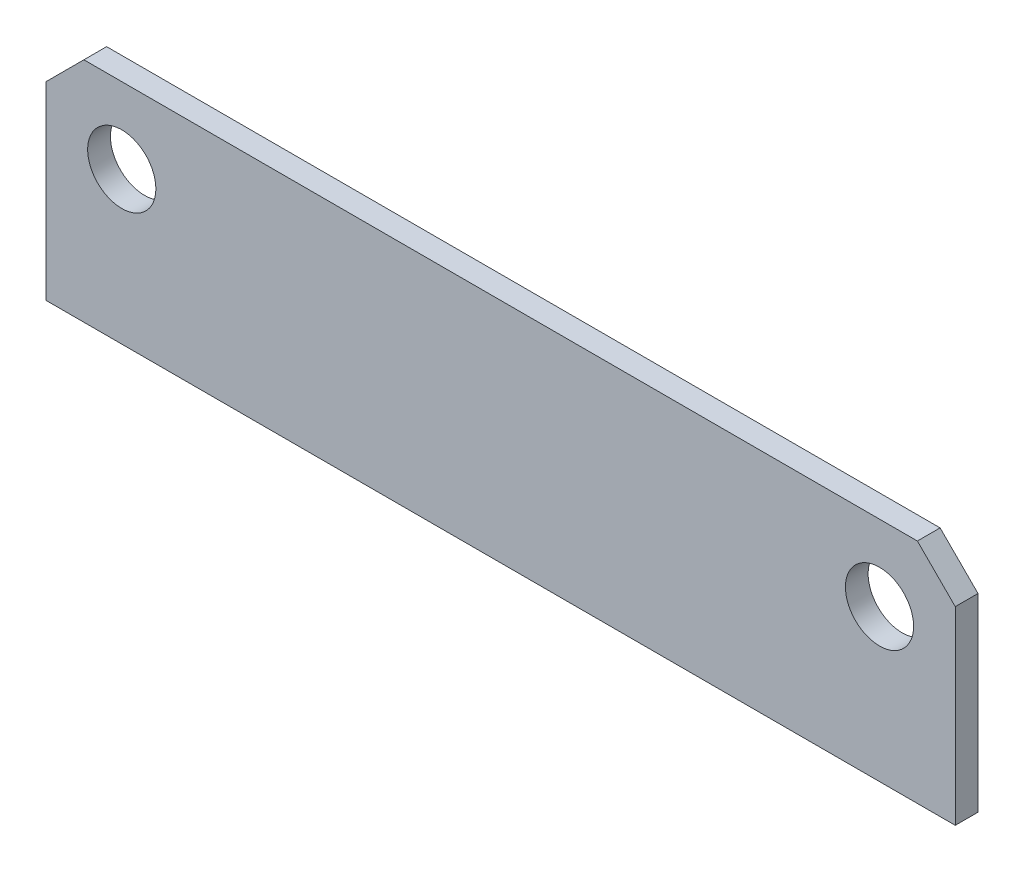
from build123d import *

# Parameters (mm, degrees)
CROQUIS1_R              = 4.5
SALIENTE_EXTRUIR1_DEPTH = 3


with BuildPart() as part:
    # Croquis1 → Saliente-Extruir1 (new body)
    with BuildSketch(Plane.XY):
        Polygon((-60, 25), (-55, 30), (55, 30), (60, 25), (60, 0), (-60, 0), align=None)
        with Locations((-50, 20)):
            Circle(CROQUIS1_R, mode=Mode.SUBTRACT)
        with Locations((50, 20)):
            Circle(CROQUIS1_R, mode=Mode.SUBTRACT)
    extrude(amount=SALIENTE_EXTRUIR1_DEPTH)


solid = part.part
